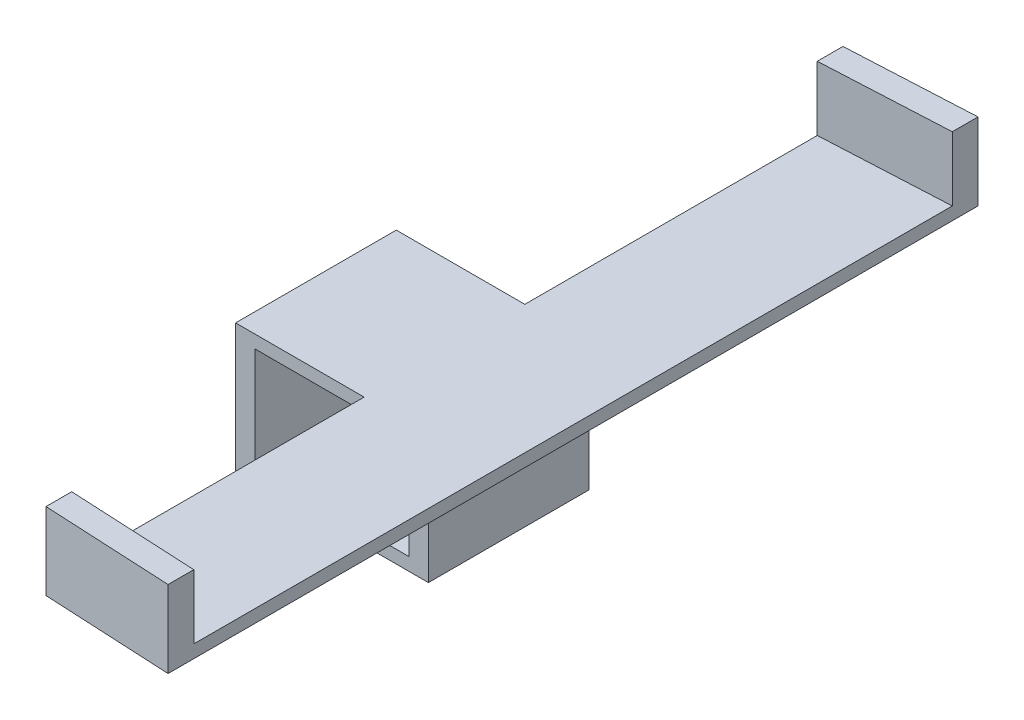
from build123d import *

# Parameters (mm, degrees)
SKETCH1_W           = 30
SKETCH1_H           = 25
SKETCH1_R           = 1.45
BOSS_EXTRUDE1_DEPTH = 18
SKETCH3_W           = 30
SKETCH3_H           = 25
BOSS_EXTRUDE2_DEPTH = 2
SKETCH4_W           = 24
SKETCH4_H           = 16
CUT_EXTRUDE2_DEPTH  = 26
SKETCH5_W           = 25
SKETCH5_H           = 2
BOSS_EXTRUDE3_DEPTH = 10
BOSS_EXTRUDE4_DEPTH = 2
BOSS_EXTRUDE5_DEPTH = 10


with BuildPart() as part:
    # Sketch1 → Boss-Extrude1 (new body)
    with BuildSketch(Plane(origin=(0, 0, 0), x_dir=(1, 0, 0), z_dir=(0, 1, 0))):
        with Locations((4.678899083, -0.940366972)):
            Rectangle(SKETCH1_W, SKETCH1_H)
        with Locations((-3.071100917, 7.559633028)):
            Circle(SKETCH1_R, mode=Mode.SUBTRACT)
        with Locations((12.428899083, 7.559633028)):
            Circle(SKETCH1_R, mode=Mode.SUBTRACT)
        with Locations((12.428899083, -9.440366972)):
            Circle(SKETCH1_R, mode=Mode.SUBTRACT)
        with Locations((-3.071100917, -9.440366972)):
            Circle(SKETCH1_R, mode=Mode.SUBTRACT)
    extrude(amount=BOSS_EXTRUDE1_DEPTH)

    # Sketch3 → Boss-Extrude2 (add)
    with BuildSketch(Plane(origin=(0, 18, 0), x_dir=(1, 0, 0), z_dir=(0, 1, 0))):
        with Locations((4.678899083, -0.940366972)):
            Rectangle(SKETCH3_W, SKETCH3_H)
    extrude(amount=BOSS_EXTRUDE2_DEPTH)

    # Sketch4 → Cut-Extrude2 (cut, through all)
    with BuildSketch(Plane.XY.offset(13.440366972)):
        with Locations((4.678899083, 10)):
            Rectangle(SKETCH4_W, SKETCH4_H)
    extrude(amount=-CUT_EXTRUDE2_DEPTH, mode=Mode.SUBTRACT)

    # Sketch5 → Boss-Extrude3 (add)
    with BuildSketch(Plane(origin=(19.678899083, 0, 0), x_dir=(0, 0, -1), z_dir=(1, 0, 0))):
        with Locations((-0.940366972, 19)):
            Rectangle(SKETCH5_W, SKETCH5_H)
    extrude(amount=BOSS_EXTRUDE3_DEPTH)

    # Sketch6 → Boss-Extrude4 (add)
    with BuildSketch(Plane(origin=(0, 20, 0), x_dir=(1, 0, 0), z_dir=(0, 1, 0))):
        Polygon((19.678899083, 11.559633028), (19.678899083, 61.559633028), (9.678899083, 61.054804674), (9.678899083, 11.559633028), align=None)
        Polygon((29.678899083, 62.064461381), (19.678899083, 61.559633028), (19.678899083, 11.559633028), (29.678899083, 11.559633028), align=None)
        Polygon((29.678899083, -13.440366972), (19.678899083, -13.440366972), (19.678899083, -63.440366972), (29.678899083, -63.945195326), align=None)
        Polygon((19.678899083, -63.440366972), (19.678899083, -13.440366972), (9.678899083, -13.440366972), (9.678899083, -62.935538619), align=None)
    extrude(amount=-BOSS_EXTRUDE4_DEPTH)

    # Sketch7 → Boss-Extrude5 (add)
    with BuildSketch(Plane(origin=(0, 20, 0), x_dir=(1, 0, 0), z_dir=(0, 1, 0))):
        Polygon((9.678899083, 61.054804674), (29.678899083, 62.064461381), (29.678899083, 58.064461381), (9.678899083, 57.054804674), align=None)
        Polygon((9.678899083, -58.935538619), (29.678899083, -59.945195326), (29.678899083, -63.945195326), (9.678899083, -62.935538619), align=None)
    extrude(amount=BOSS_EXTRUDE5_DEPTH)


solid = part.part
